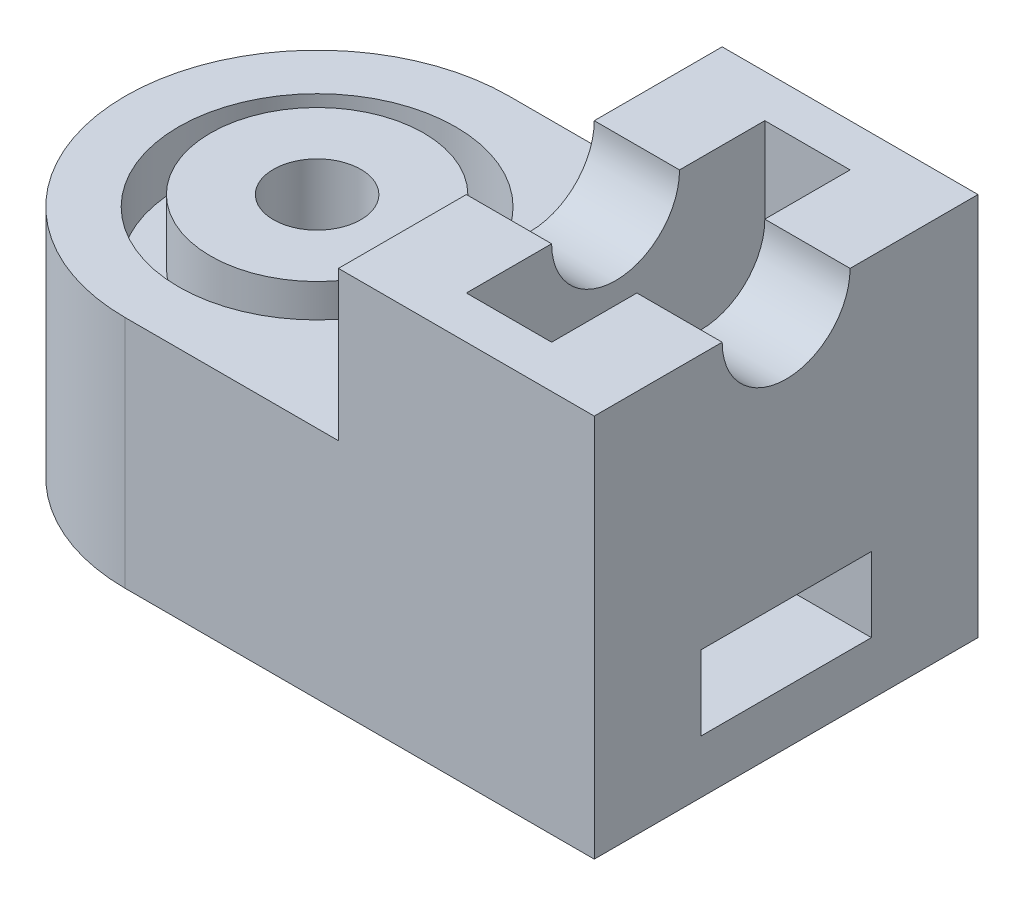
from build123d import *

# Parameters (mm, degrees)
SKETCH2_W               = 11
SKETCH2_H               = 9
BOSS_EXTRUDE1_DEPTH     = 9
SKETCH3_W               = 15.859827236
SKETCH3_H               = 9.999542671
CUT_EXTRUDE1_DEPTH      = 3.5
CUT_EXTRUDE2_DEPTH      = 13.5
SKETCH5_W               = 2
SKETCH5_H               = 7
CUT_EXTRUDE3_DEPTH      = 28.773973587
SKETCH6_R               = 3.25
CUT_EXTRUDE4_DEPTH      = 1.25
SKETCH7_R               = 2.5
BOSS_EXTRUDE2_DEPTH     = 1.5
SKETCH8_W               = 4
SKETCH8_H               = 1.75
CUT_EXTRUDE5_DEPTH      = 21.5
SKETCH9_W               = 6
SKETCH9_H               = 2.75
CUT_EXTRUDE6_DEPTH      = 4.5
M2_5_TAPPED_HOLE2_D     = 2.05
M2_5_TAPPED_HOLE2_DEPTH = 3
M2_5_TAPPED_HOLE2_TIP   = 0.615882135
SKETCH11_W              = 2.05
SKETCH11_H              = 0.5
BOSS_EXTRUDE3_DEPTH     = 4


with BuildPart() as part:
    # Sketch2 → Boss-Extrude1 (new body)
    with BuildSketch(Plane(origin=(0, 0, 0), x_dir=(1, 0, 0), z_dir=(0, 1, 0))):
        with BuildLine():
            Line((-5.5, -4.5), (-5.5, 4.5))
            ThreePointArc((-5.5, 4.5), (-10, 0), (-5.5, -4.5))
        make_face()
        Rectangle(SKETCH2_W, SKETCH2_H)
    extrude(amount=BOSS_EXTRUDE1_DEPTH)

    # Sketch3 → Cut-Extrude1 (cut)
    with BuildSketch(Plane(origin=(0, 9, 0), x_dir=(1, 0, 0), z_dir=(0, 1, 0))):
        with Locations((-8.429913618, -0.499771336)):
            Rectangle(SKETCH3_W, SKETCH3_H)
    extrude(amount=-CUT_EXTRUDE1_DEPTH, mode=Mode.SUBTRACT)

    # Sketch4 → Cut-Extrude2 (cut)
    with BuildSketch(Plane.ZY.offset(0.5)):
        with BuildLine():
            Line((-1.5, 9), (1.5, 9))
            ThreePointArc((1.5, 9), (0, 7.5), (-1.5, 9))
        make_face()
    extrude(amount=-CUT_EXTRUDE2_DEPTH, mode=Mode.SUBTRACT)

    # Sketch5 → Cut-Extrude3 (cut)
    with BuildSketch(Plane(origin=(0, 9, 0), x_dir=(1, 0, 0), z_dir=(0, 1, 0))):
        with Locations((2.5, 0)):
            Rectangle(SKETCH5_W, SKETCH5_H)
    extrude(amount=-CUT_EXTRUDE3_DEPTH, mode=Mode.SUBTRACT)

    # Sketch6 → Cut-Extrude4 (cut)
    with BuildSketch(Plane(origin=(0, 5.5, 0), x_dir=(1, 0, 0), z_dir=(0, 1, 0))):
        with Locations((-5.5, 0)):
            Circle(SKETCH6_R)
    extrude(amount=-CUT_EXTRUDE4_DEPTH, mode=Mode.SUBTRACT)

    # Sketch7 → Boss-Extrude2 (add)
    with BuildSketch(Plane(origin=(0, 4.25, 0), x_dir=(1, 0, 0), z_dir=(0, 1, 0))):
        with Locations((-5.5, 0)):
            Circle(SKETCH7_R)
    extrude(amount=BOSS_EXTRUDE2_DEPTH)

    # Sketch8 → Cut-Extrude5 (cut)
    with BuildSketch(Plane(origin=(5.5, 0, 0), x_dir=(0, 0, -1), z_dir=(1, 0, 0))):
        with Locations((0, 2.125)):
            Rectangle(SKETCH8_W, SKETCH8_H)
    extrude(amount=-CUT_EXTRUDE5_DEPTH, mode=Mode.SUBTRACT)

    # Sketch9 → Cut-Extrude6 (cut)
    with BuildSketch(Plane(origin=(-10, 0, 0), x_dir=(0, 0, -1), z_dir=(1, 0, 0))):
        with Locations((0, 2.125)):
            Rectangle(SKETCH9_W, SKETCH9_H)
    extrude(amount=CUT_EXTRUDE6_DEPTH, mode=Mode.SUBTRACT)

    # M2.5 Tapped Hole2
    with Locations(Plane(origin=(-5.5, 5.75, 0), x_dir=(0, 0, 1), z_dir=(0, 1, 0))):
        with Locations((0, 0)):
            Hole(M2_5_TAPPED_HOLE2_D / 2, depth=M2_5_TAPPED_HOLE2_DEPTH)
            with Locations((0, 0, -(M2_5_TAPPED_HOLE2_DEPTH + M2_5_TAPPED_HOLE2_TIP / 2))):  # 118° drill point
                Cone(0, M2_5_TAPPED_HOLE2_D / 2, M2_5_TAPPED_HOLE2_TIP, mode=Mode.SUBTRACT)

    # Sketch11 → Boss-Extrude3 (add)
    with BuildSketch(Plane.ZY.offset(5.5)):
        with Locations((0, 3.25)):
            Rectangle(SKETCH11_W, SKETCH11_H)
    extrude(amount=-BOSS_EXTRUDE3_DEPTH)


solid = part.part
